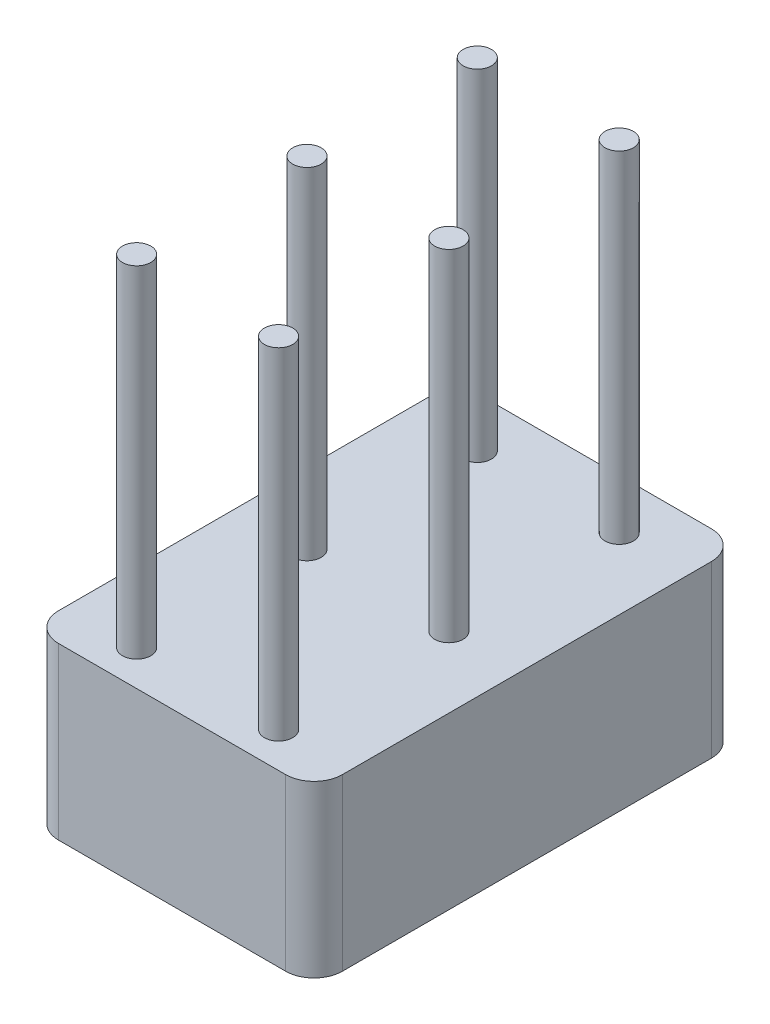
from build123d import *

# Parameters (mm, degrees)
BOSS_EXTRUDE1_DEPTH = 3
SKETCH2_R           = 0.25
BOSS_EXTRUDE2_DEPTH = 6


with BuildPart() as part:
    # Sketch1 → Boss-Extrude1 (new body)
    with BuildSketch(Plane(origin=(0, 0, 0), x_dir=(1, 0, 0), z_dir=(0, 1, 0))):
        with BuildLine():
            Line((-2, 3.75), (2, 3.75))
            ThreePointArc((2, 3.75), (2.353553391, 3.603553391), (2.5, 3.25))
            Line((2.5, 3.25), (2.5, -3.25))
            ThreePointArc((2.5, -3.25), (2.353553391, -3.603553391), (2, -3.75))
            Line((2, -3.75), (-2, -3.75))
            ThreePointArc((-2, -3.75), (-2.353553391, -3.603553391), (-2.5, -3.25))
            Line((-2.5, -3.25), (-2.5, 3.25))
            ThreePointArc((-2.5, 3.25), (-2.353553391, 3.603553391), (-2, 3.75))
        make_face()
    extrude(amount=BOSS_EXTRUDE1_DEPTH)

    # Sketch2 → Boss-Extrude2 (add)
    with BuildSketch(Plane(origin=(0, 3, 0), x_dir=(1, 0, 0), z_dir=(0, 1, 0))):
        with Locations((-1.25, 2.875448281)):
            Circle(SKETCH2_R)
        with Locations((1.25, 2.875448281)):
            Circle(SKETCH2_R)
        with Locations((-1.25, -0.124551719)):
            Circle(SKETCH2_R)
        with Locations((1.25, -0.124551719)):
            Circle(SKETCH2_R)
        with Locations((-1.25, -3.124551719)):
            Circle(SKETCH2_R)
        with Locations((1.25, -3.124551719)):
            Circle(SKETCH2_R)
    extrude(amount=BOSS_EXTRUDE2_DEPTH)


solid = part.part
